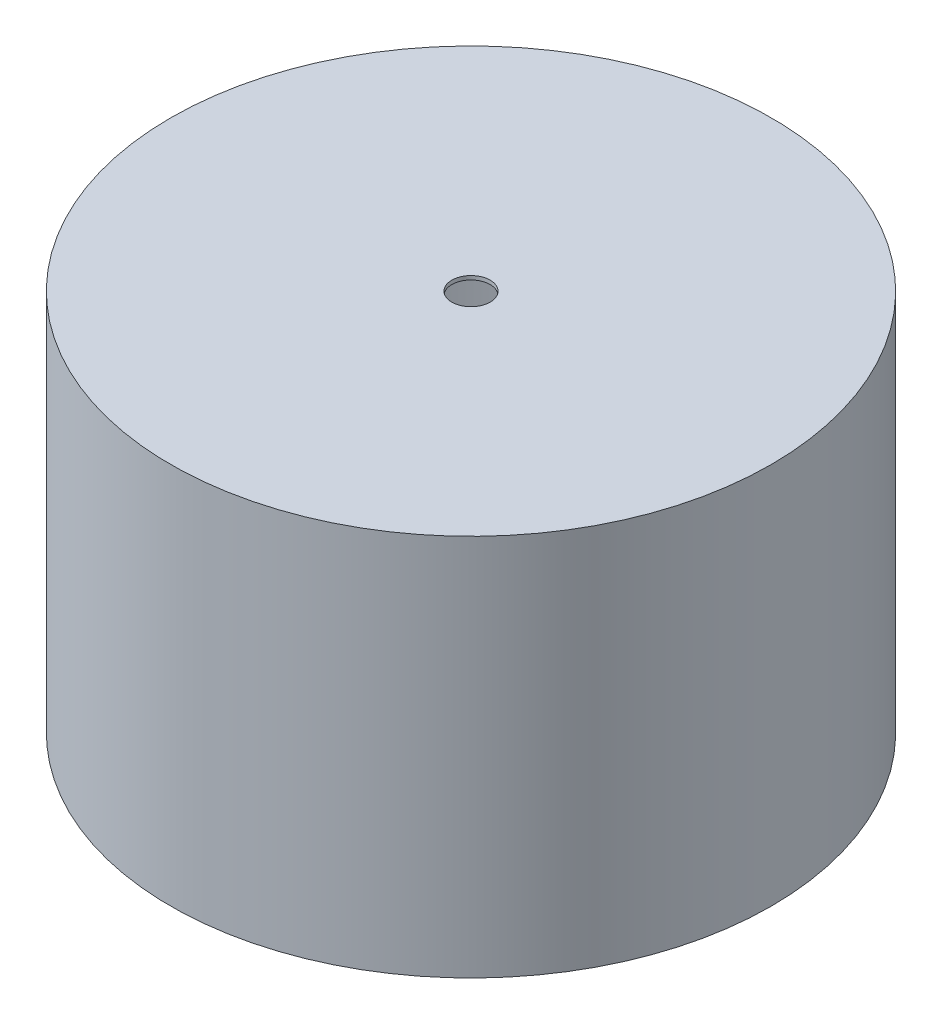
from build123d import *

# Parameters (mm, degrees)
SKETCH1_R           = 77.5
BOSS_EXTRUDE1_DEPTH = 1
SKETCH1_2_R         = 78.5
SKETCH1_2_R_2       = 77.5
EXTRUDE_THIN1_DEPTH = 100
SKETCH2_R           = 5
CUT_EXTRUDE1_DEPTH  = 150.413854779


with BuildPart() as part:
    # Sketch1 → Boss-Extrude1 (new body)
    with BuildSketch(Plane(origin=(0, 0, 0), x_dir=(1, 0, 0), z_dir=(0, 1, 0))):
        Circle(SKETCH1_R)
    extrude(amount=-BOSS_EXTRUDE1_DEPTH)

    # Sketch1_2 → Extrude-Thin1 (add)
    with BuildSketch(Plane(origin=(0, 0, 0), x_dir=(1, 0, 0), z_dir=(0, 1, 0))):
        Circle(SKETCH1_2_R)
        Circle(SKETCH1_2_R_2, mode=Mode.SUBTRACT)
    extrude(amount=-EXTRUDE_THIN1_DEPTH)

    # Sketch2 → Cut-Extrude1 (cut, through all)
    with BuildSketch(Plane(origin=(0, 0, 0), x_dir=(1, 0, 0), z_dir=(0, 1, 0))):
        Circle(SKETCH2_R)
    extrude(amount=-CUT_EXTRUDE1_DEPTH, mode=Mode.SUBTRACT)


solid = part.part
